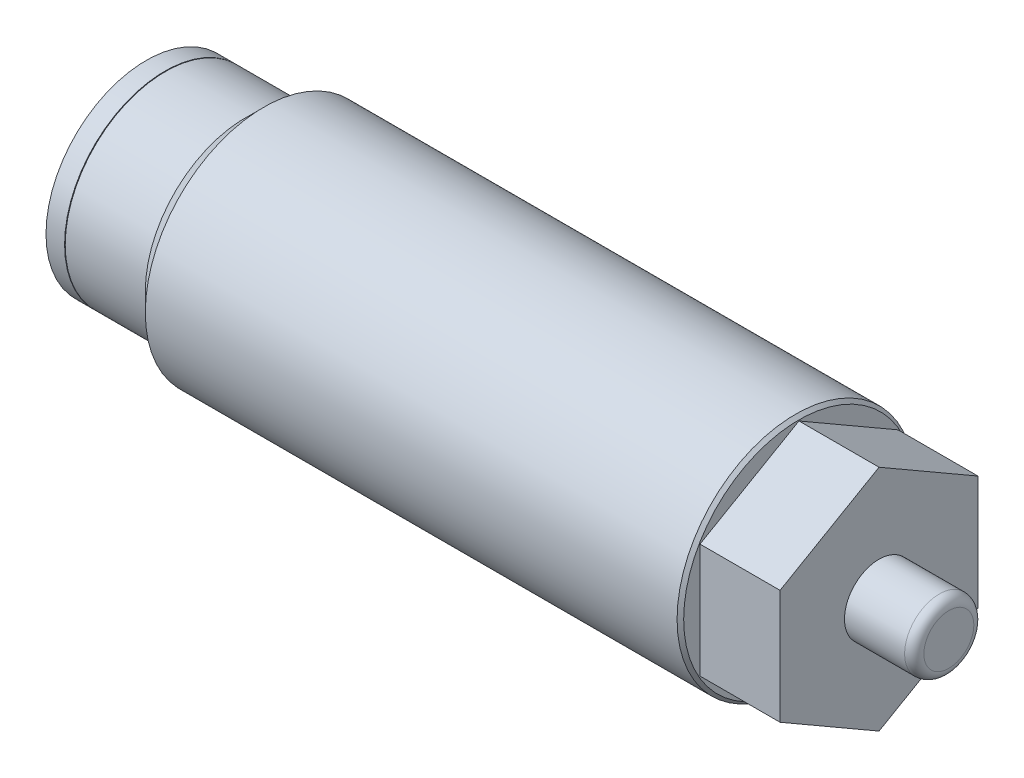
from build123d import *

# Parameters (mm, degrees)
SKETCH11_W     = 0.7366
SKETCH11_H     = 2.0701
EXTRUDE3_DEPTH = 3.175
SKETCH14_W     = 2.7686
SKETCH14_H     = 1.3716
SKETCH15_W     = 2.4892
SKETCH15_H     = 0.254
CHAMFER3_SIZE  = 0.13081
FILLET3_R      = 0.381


with BuildPart() as part:
    # Sketch11 → Revolve5 (revolve)
    with BuildSketch(Plane.XY, mode=Mode.PRIVATE) as revolve5_sk:
        with Locations((-0.3937, 2.94005)):
            Rectangle(SKETCH11_W, SKETCH11_H)
    revolve(revolve5_sk.sketch.rotate(Axis((-0.762, 0, 0), (1, 0, 0)), 270), axis=Axis((-0.762, 0, 0), (1, 0, 0)))  # turned: the seam where the file's is


with BuildPart() as body_2:
    # Sketch12 → Revolve6 (revolve)
    with BuildSketch(Plane(origin=(0, 0, 0), x_dir=(-1, 0, 0), z_dir=(0, 0, -1)), mode=Mode.PRIVATE) as revolve6_sk:
        Polygon((-25.1206, 4.70281), (-25.1206, 0), (0, 0), (0, 3.9751), (-3.175, 3.9751), (-3.90271, 4.70281), align=None)
    revolve(revolve6_sk.sketch.rotate(Axis((30.602542541, 0, 0), (-1, 0, 0)), 270), axis=Axis((30.602542541, 0, 0), (-1, 0, 0)))  # turned: the seam where the file's is

    # Sketch15 → Hole3 (revolve, cut)
    with BuildSketch(Plane.ZX):
        with Locations((1.2446, 0.127)):
            Rectangle(SKETCH15_W, SKETCH15_H)
    revolve(axis=Axis((110, 0, 0), (-1, 0, 0)), mode=Mode.SUBTRACT)

    # Chamfer3
    chamfer3_edges = [body_2.edges().sort_by_distance(p)[0] for p in [
        (25.1206, 0, -4.70281),
    ]]
    chamfer(chamfer3_edges, length=CHAMFER3_SIZE)


with BuildPart() as body_3:
    # Sketch13 → Extrude3 (new body)
    with BuildSketch(Plane(origin=(25.1206, 0, 0), x_dir=(0, 0, -1), z_dir=(1, 0, 0))):
        Polygon((3.9243, 2.265695661), (0, 4.531391323), (-3.9243, 2.265695661), (-3.9243, -2.265695661), (0, -4.531391323), (3.9243, -2.265695661), align=None)
    extrude(amount=EXTRUDE3_DEPTH)


with BuildPart() as body_4:
    # Sketch14 → Revolve7 (revolve)
    with BuildSketch(Plane.XY, mode=Mode.PRIVATE) as revolve7_sk:
        with Locations((29.6799, 0.6858)):
            Rectangle(SKETCH14_W, SKETCH14_H)
    revolve(revolve7_sk.sketch.rotate(Axis((28.2956, 0, 0), (1, 0, 0)), 270), axis=Axis((28.2956, 0, 0), (1, 0, 0)))  # turned: the seam where the file's is

    # Fillet3
    fillet3_edges = [body_4.edges().sort_by_distance(p)[0] for p in [
        (31.0642, 0, 1.3716),
    ]]
    fillet(fillet3_edges, radius=FILLET3_R)


solid = Compound([part.part, body_2.part, body_3.part, body_4.part])
